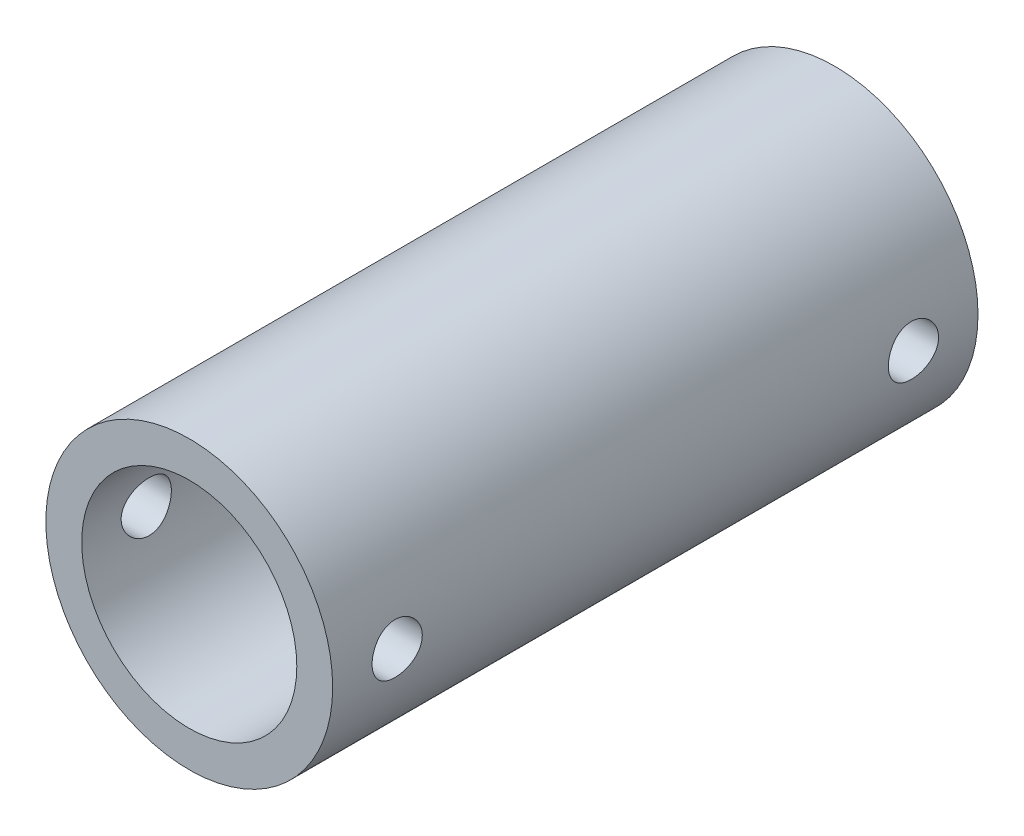
from build123d import *

# Parameters (mm, degrees)
SKETCH1_R               = 40
SKETCH1_R_2             = 30
BOSS_EXTRUDE1_DEPTH     = 90
SKETCH2_R               = 7
CUT_EXTRUDE1_DEPTH      = 41
CUT_EXTRUDE1_DEPTH_BACK = 41


with BuildPart() as part:
    # Sketch1 → Boss-Extrude1 (new body, symmetric)
    with BuildSketch(Plane.XY):
        Circle(SKETCH1_R)
        Circle(SKETCH1_R_2, mode=Mode.SUBTRACT)
    extrude(amount=BOSS_EXTRUDE1_DEPTH, both=True)

    # Sketch2 → Cut-Extrude1 (cut, two sides)
    with BuildSketch(Plane(origin=(0, 0, 0), x_dir=(0, 0, -1), z_dir=(1, 0, 0))) as cut_extrude1_sk:
        with Locations((-72, 0)):
            Circle(SKETCH2_R)
        with Locations((72, 0)):
            Circle(SKETCH2_R)
    extrude(amount=CUT_EXTRUDE1_DEPTH, mode=Mode.SUBTRACT)
    extrude(cut_extrude1_sk.sketch, amount=-CUT_EXTRUDE1_DEPTH_BACK, mode=Mode.SUBTRACT)


solid = part.part
